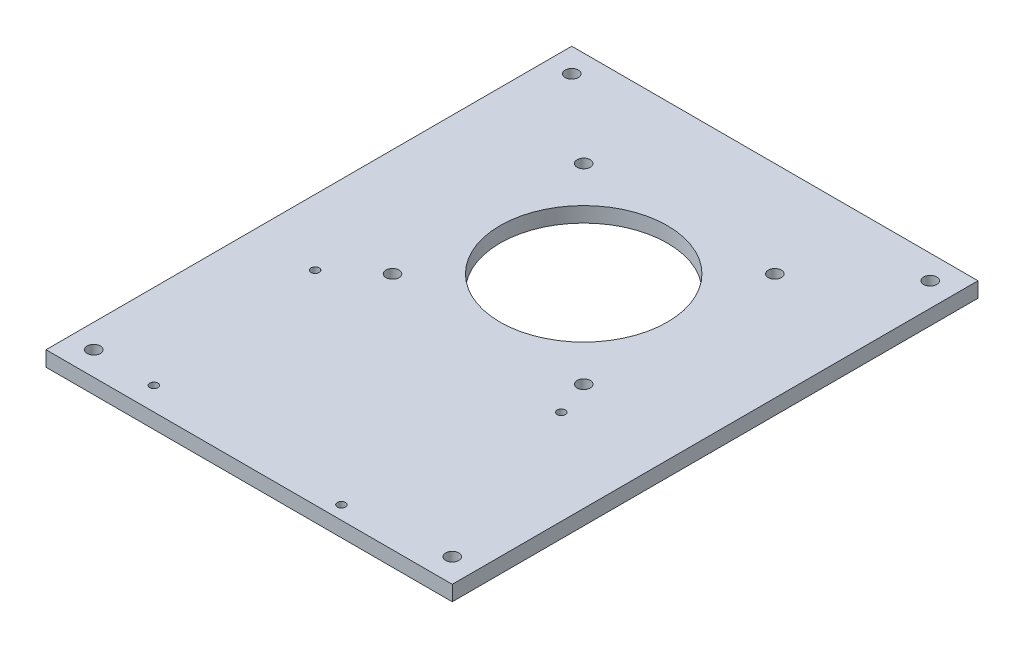
from build123d import *

# Parameters (mm, degrees)
SKETCH2_W                                       = 170
SKETCH2_H                                       = 220
SKETCH2_R                                       = 35
SKETCH2_R_2                                     = 2.75
BOSS_EXTRUDE1_DEPTH                             = 6.35
CSK_FOR_M3_FLAT_HEAD_MACHINE_SCREW2_D           = 3.4
CSK_FOR_M3_FLAT_HEAD_MACHINE_SCREW2_CSINK_D     = 6.3
CSK_FOR_M3_FLAT_HEAD_MACHINE_SCREW2_CSINK_ANGLE = 90


with BuildPart() as part:
    # Sketch2 → Boss-Extrude1 (new body)
    with BuildSketch(Plane(origin=(0, 0, 0), x_dir=(1, 0, 0), z_dir=(0, 1, 0))):
        with Locations((0, -30)):
            Rectangle(SKETCH2_W, SKETCH2_H)
        Circle(SKETCH2_R, mode=Mode.SUBTRACT)
        with Locations((-40, 40)):
            Circle(SKETCH2_R_2, mode=Mode.SUBTRACT)
        with Locations((40, 40)):
            Circle(SKETCH2_R_2, mode=Mode.SUBTRACT)
        with Locations((40, -40)):
            Circle(SKETCH2_R_2, mode=Mode.SUBTRACT)
        with Locations((-40, -40)):
            Circle(SKETCH2_R_2, mode=Mode.SUBTRACT)
        with Locations((-75, 70)):
            Circle(SKETCH2_R_2, mode=Mode.SUBTRACT)
        with Locations((-75, -130)):
            Circle(SKETCH2_R_2, mode=Mode.SUBTRACT)
        with Locations((75, 70)):
            Circle(SKETCH2_R_2, mode=Mode.SUBTRACT)
        with Locations((75, -130)):
            Circle(SKETCH2_R_2, mode=Mode.SUBTRACT)
    extrude(amount=BOSS_EXTRUDE1_DEPTH)

    # CSK for M3 Flat Head Machine Screw2 (through all)
    with Locations(Plane(origin=(0, 0, 0), x_dir=(-1, 0, 0), z_dir=(0, -1, 0))):
        with Locations((57.523089764, -54.859977456), (-45.476910236, -54.859977456), (-32.976910236, -134.359977456), (49.523089764, -130.359977456)):
            CounterSinkHole(CSK_FOR_M3_FLAT_HEAD_MACHINE_SCREW2_D / 2, CSK_FOR_M3_FLAT_HEAD_MACHINE_SCREW2_CSINK_D / 2, counter_sink_angle=CSK_FOR_M3_FLAT_HEAD_MACHINE_SCREW2_CSINK_ANGLE)


solid = part.part
